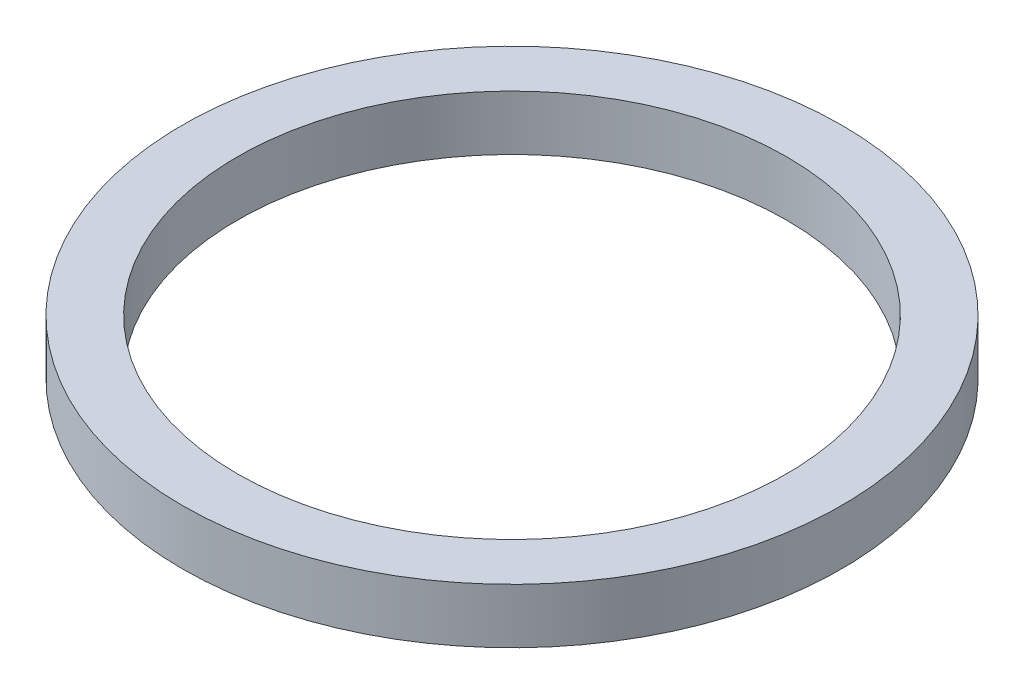
from build123d import *

# Parameters (mm, degrees)
SKETCH1_R           = 30
SKETCH1_R_2         = 25
BOSS_EXTRUDE1_DEPTH = 5


with BuildPart() as part:
    # Sketch1 → Boss-Extrude1 (new body)
    with BuildSketch(Plane(origin=(0, 0, 0), x_dir=(1, 0, 0), z_dir=(0, 1, 0))):
        Circle(SKETCH1_R)
        Circle(SKETCH1_R_2, mode=Mode.SUBTRACT)
    extrude(amount=BOSS_EXTRUDE1_DEPTH)


solid = part.part
